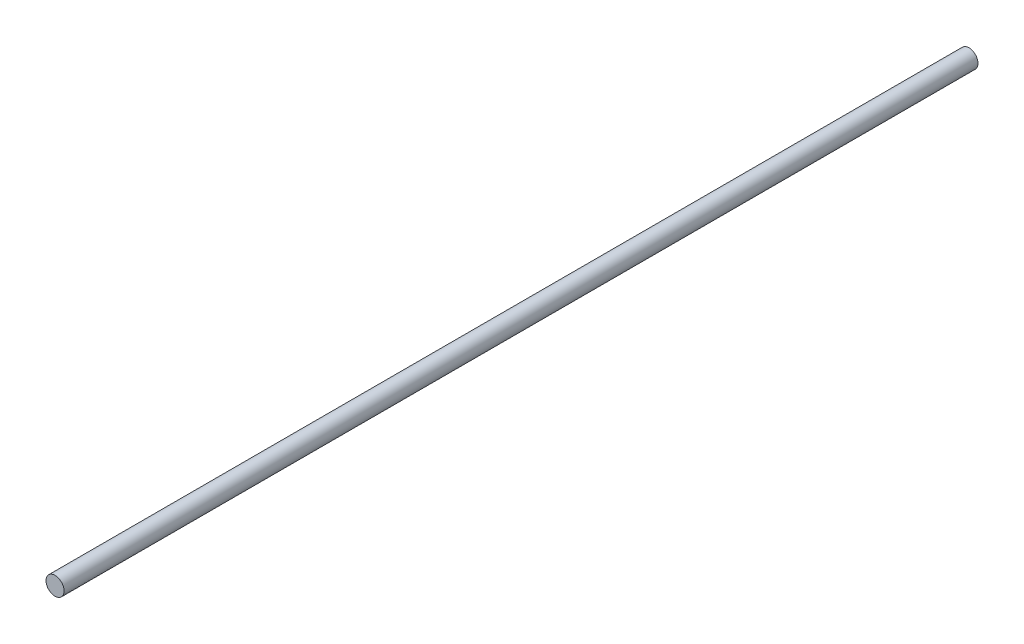
from build123d import *

# Parameters (mm, degrees)
CROQUIS1_R              = 6
SALIENTE_EXTRUIR1_DEPTH = 605.8


with BuildPart() as part:
    # Croquis1 → Saliente-Extruir1 (new body)
    with BuildSketch(Plane.XY):
        Circle(CROQUIS1_R)
    extrude(amount=SALIENTE_EXTRUIR1_DEPTH)


solid = part.part
